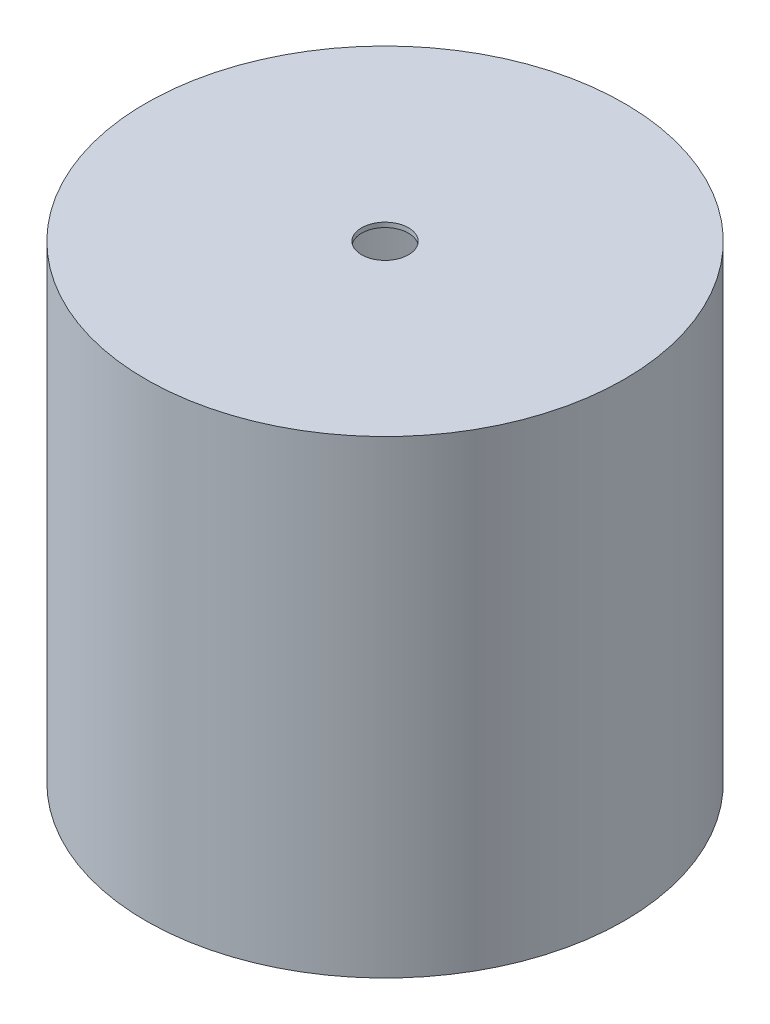
from build123d import *

# Parameters (mm, degrees)
SKETCH1_R           = 51
SKETCH1_R_2         = 50
EXTRUDE_THIN1_DEPTH = 100
SKETCH1_2_R         = 50
BOSS_EXTRUDE1_DEPTH = 1
LPATTERN1_COUNT     = 2
LPATTERN1_PITCH     = 99
SKETCH3_R           = 5
CUT_EXTRUDE1_DEPTH  = 124.296390864


with BuildPart() as part:
    # Sketch1 → Extrude-Thin1 (new body)
    with BuildSketch(Plane(origin=(0, 0, 0), x_dir=(1, 0, 0), z_dir=(0, 1, 0))):
        Circle(SKETCH1_R)
        Circle(SKETCH1_R_2, mode=Mode.SUBTRACT)
    extrude(amount=EXTRUDE_THIN1_DEPTH)

    # Sketch1_2 → Boss-Extrude1 (add)
    with BuildSketch(Plane(origin=(0, 0, 0), x_dir=(1, 0, 0), z_dir=(0, 1, 0))):
        Circle(SKETCH1_2_R)
    boss_extrude1 = extrude(amount=BOSS_EXTRUDE1_DEPTH)

    # LPattern1: Boss-Extrude1 ×2
    with Locations(*[(0, i * LPATTERN1_PITCH, 0) for i in range(1, LPATTERN1_COUNT)]):
        add(boss_extrude1)

    # Sketch3 → Cut-Extrude1 (cut, through all)
    with BuildSketch(Plane.XZ):
        Circle(SKETCH3_R)
    extrude(amount=-CUT_EXTRUDE1_DEPTH, mode=Mode.SUBTRACT)


solid = part.part
